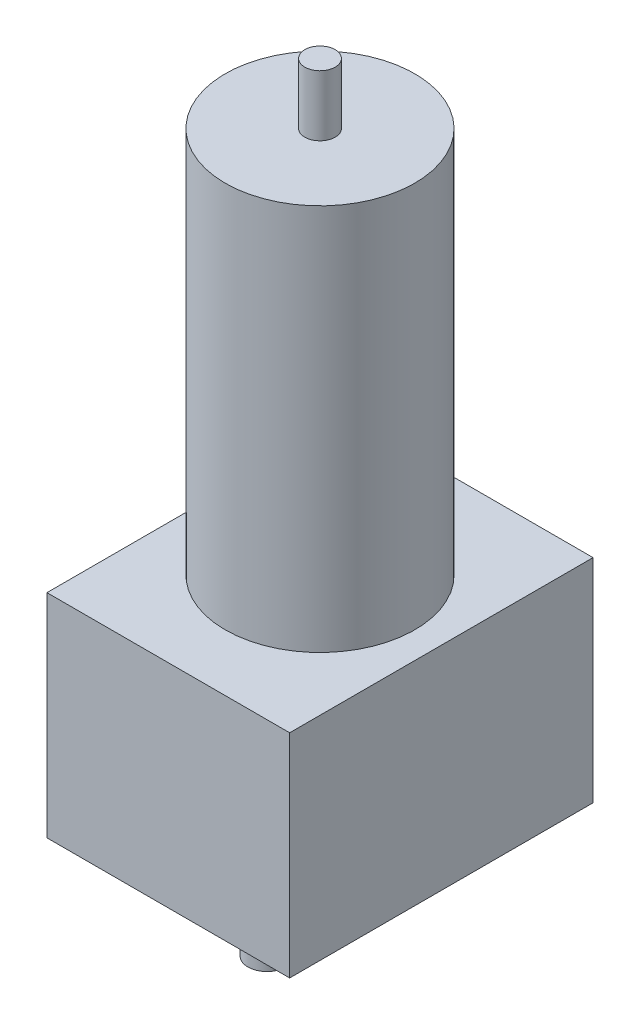
from build123d import *

# Parameters (mm, degrees)
SKETCH1_W           = 101.6
SKETCH1_H           = 127
BOSS_EXTRUDE2_DEPTH = 88.9
SKETCH3_R           = 39.6875
BOSS_EXTRUDE3_DEPTH = 161.925
SKETCH4_R           = 6.35
BOSS_EXTRUDE4_DEPTH = 25.4
SKETCH5_R           = 7.9375
BOSS_EXTRUDE5_DEPTH = 38.1
SKETCH6_R           = 3.96875
CUT_EXTRUDE1_DEPTH  = 25.4


with BuildPart() as part:
    # Sketch1 → Boss-Extrude2 (new body)
    with BuildSketch(Plane(origin=(0, 0, 0), x_dir=(1, 0, 0), z_dir=(0, 1, 0))):
        Rectangle(SKETCH1_W, SKETCH1_H)
    extrude(amount=BOSS_EXTRUDE2_DEPTH)

    # Sketch3 → Boss-Extrude3 (add)
    with BuildSketch(Plane(origin=(0, 88.9, 0), x_dir=(1, 0, 0), z_dir=(0, 1, 0))):
        Circle(SKETCH3_R)
    extrude(amount=BOSS_EXTRUDE3_DEPTH)

    # Sketch4 → Boss-Extrude4 (add)
    with BuildSketch(Plane(origin=(0, 250.825, 0), x_dir=(1, 0, 0), z_dir=(0, 1, 0))):
        Circle(SKETCH4_R)
    extrude(amount=BOSS_EXTRUDE4_DEPTH)

    # Sketch5 → Boss-Extrude5 (add)
    with BuildSketch(Plane(origin=(0, 0, 0), x_dir=(-1, 0, 0), z_dir=(0, -1, 0))):
        with Locations((0, -22.225)):
            Circle(SKETCH5_R)
    extrude(amount=BOSS_EXTRUDE5_DEPTH)

    # Sketch6 → Cut-Extrude1 (cut)
    with BuildSketch(Plane(origin=(0, 0, 0), x_dir=(-1, 0, 0), z_dir=(0, -1, 0))):
        with Locations((42.8625, -38.1)):
            Circle(SKETCH6_R)
        with Locations((-42.8625, -38.1)):
            Circle(SKETCH6_R)
        with Locations((42.8625, 50.174061918)):
            Circle(SKETCH6_R)
        with Locations((-42.8625, 50.174061918)):
            Circle(SKETCH6_R)
    extrude(amount=-CUT_EXTRUDE1_DEPTH, mode=Mode.SUBTRACT)


solid = part.part
